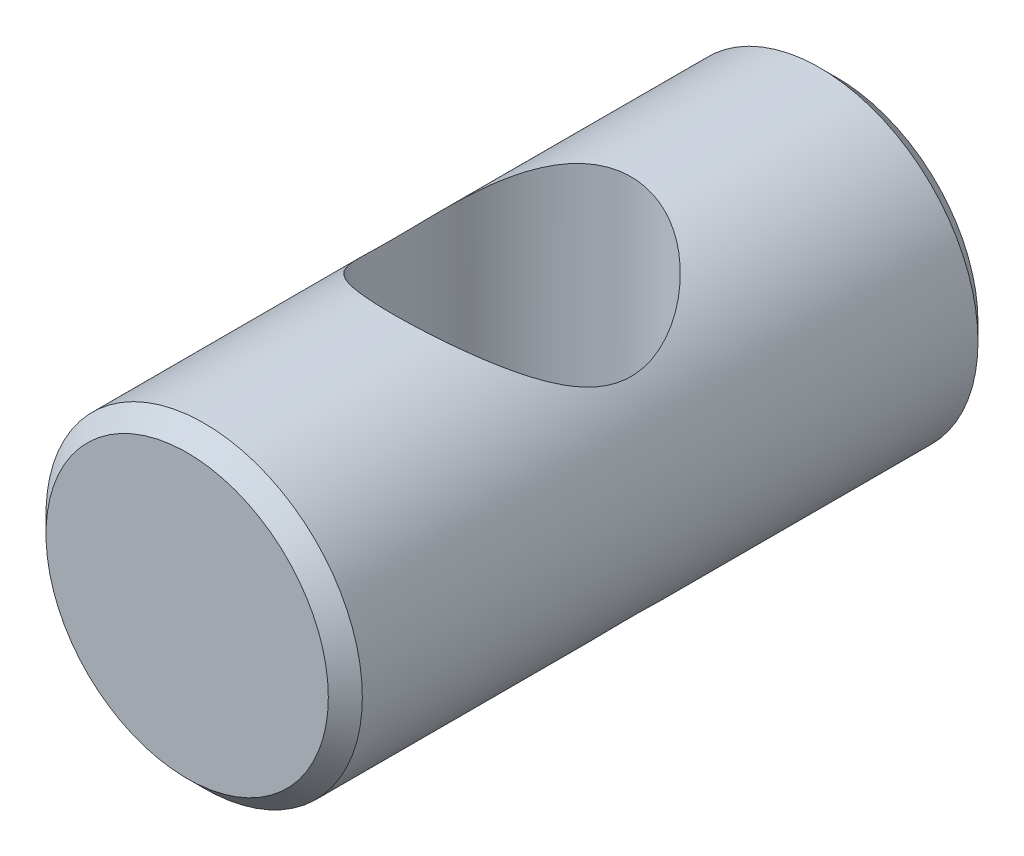
from build123d import *

# Parameters (mm, degrees)
SKETCH1_R               = 4.65
BOSS_EXTRUDE1_DEPTH     = 19.1
SKETCH2_R               = 3.5
CUT_EXTRUDE1_DEPTH      = 5.65
CUT_EXTRUDE1_DEPTH_BACK = 5.65
CHAMFER1_SIZE           = 0.5


with BuildPart() as part:
    # Sketch1 → Boss-Extrude1 (new body)
    with BuildSketch(Plane.XY):
        Circle(SKETCH1_R)
    extrude(amount=BOSS_EXTRUDE1_DEPTH)

    # Sketch2 → Cut-Extrude1 (cut, two sides)
    with BuildSketch(Plane(origin=(0, 0, 0), x_dir=(1, 0, 0), z_dir=(0, 1, 0))) as cut_extrude1_sk:
        with Locations((0, -9.55)):
            Circle(SKETCH2_R)
    extrude(amount=CUT_EXTRUDE1_DEPTH, mode=Mode.SUBTRACT)
    extrude(cut_extrude1_sk.sketch, amount=-CUT_EXTRUDE1_DEPTH_BACK, mode=Mode.SUBTRACT)

    # Chamfer1
    chamfer1_edges = [part.edges().sort_by_distance(p)[0] for p in [
        (-4.65, 0, 0),
        (-4.65, 0, 19.1),
    ]]
    chamfer(chamfer1_edges, length=CHAMFER1_SIZE)


solid = part.part
